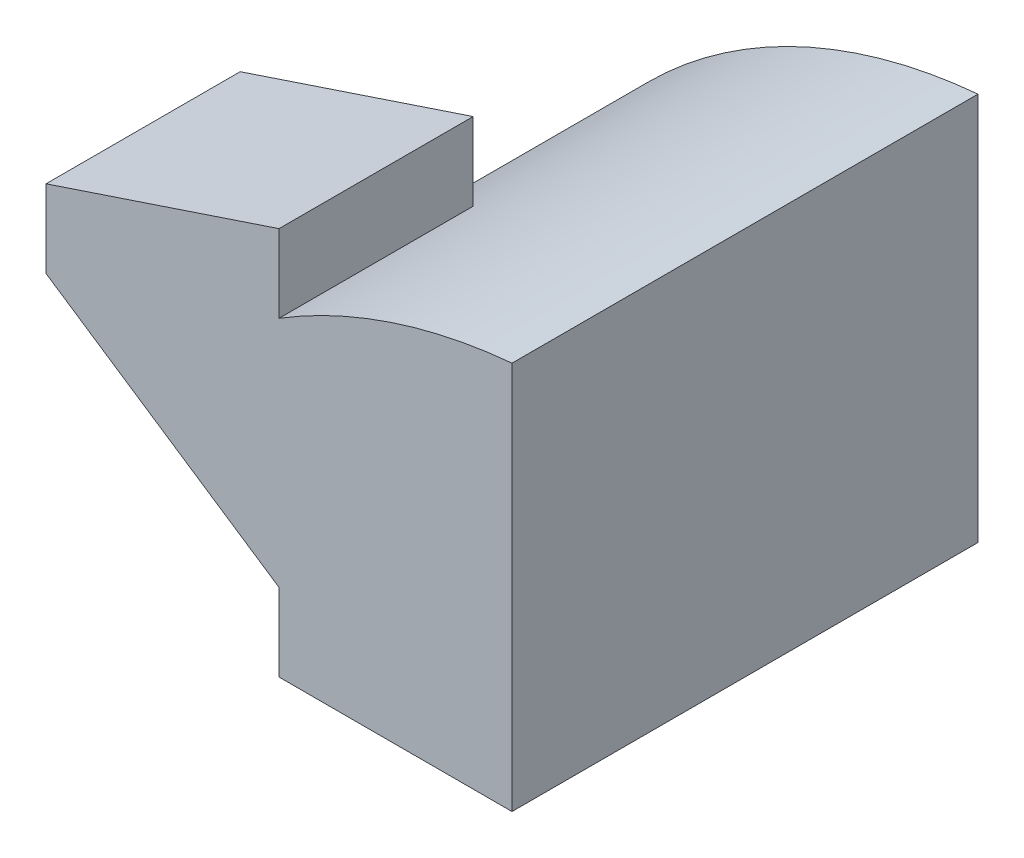
from build123d import *

# Parameters (mm, degrees)
SKETCH1_W           = 6
SKETCH1_H           = 6
BOSS_EXTRUDE1_DEPTH = 5
CUT_EXTRUDE12_DEPTH = 3.5
CUT_EXTRUDE13_DEPTH = 3.5
CUT_EXTRUDE14_DEPTH = 3.5


with BuildPart() as part:
    # Sketch1 → Boss-Extrude1 (new body)
    with BuildSketch(Plane(origin=(0, 0, 0), x_dir=(1, 0, 0), z_dir=(0, 1, 0))):
        Rectangle(SKETCH1_W, SKETCH1_H)
    extrude(amount=BOSS_EXTRUDE1_DEPTH)

    # Sketch13 → Cut-Extrude12 (cut)
    with BuildSketch(Plane(origin=(0, 0, -3), x_dir=(-1, 0, 0), z_dir=(0, 0, -1))):
        with BuildLine():
            ThreePointArc((-3, 5), (0.780941195, 3.437129434), (3, 0))
            Line((3, 0), (3, 5))
            Line((3, 5), (-3, 5))
        make_face()
    extrude(amount=-CUT_EXTRUDE12_DEPTH, mode=Mode.SUBTRACT)

    # Sketch14 → Cut-Extrude13 (cut)
    with BuildSketch(Plane(origin=(0, 0, 0.5), x_dir=(-1, 0, 0), z_dir=(0, 0, -1))):
        with BuildLine():
            ThreePointArc((-3, 5), (-1.441597312, 4.675208063), (0, 4))
            Line((0, 4), (0, 5))
            Line((0, 5), (-3, 5))
        make_face()
    extrude(amount=-CUT_EXTRUDE13_DEPTH, mode=Mode.SUBTRACT)

    # Sketch15 → Cut-Extrude14 (cut)
    with BuildSketch(Plane.XY.offset(3)):
        Polygon((-3, 4), (0, 5), (-3, 5), align=None)
        Polygon((0, 1), (-3, 3), (-3, 0), (0, 0), align=None)
    extrude(amount=-CUT_EXTRUDE14_DEPTH, mode=Mode.SUBTRACT)


solid = part.part
